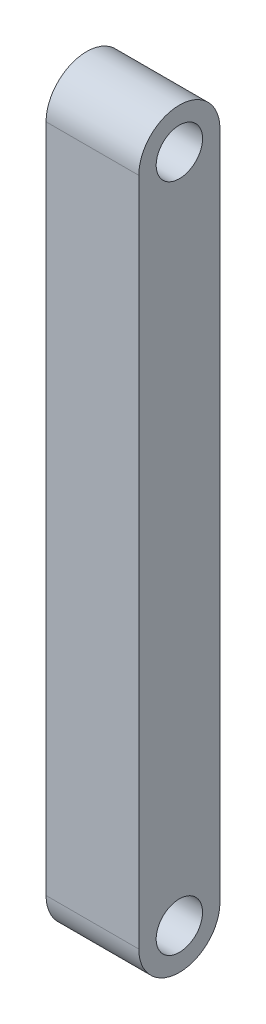
from build123d import *

# Parameters (mm, degrees)
SKETCH1_R           = 2
BOSS_EXTRUDE1_DEPTH = 8


with BuildPart() as part:
    # Sketch1 → Boss-Extrude1 (new body)
    with BuildSketch(Plane(origin=(0, 0, 0), x_dir=(0, 0, -1), z_dir=(1, 0, 0))):
        with BuildLine():
            Line((3.5, -57.8), (3.5, 0))
            ThreePointArc((3.5, 0), (0, 3.5), (-3.5, 0))
            Line((-3.5, 0), (-3.5, -57.8))
            ThreePointArc((-3.5, -57.8), (0, -61.3), (3.5, -57.8))
        make_face()
        Circle(SKETCH1_R, mode=Mode.SUBTRACT)
        with Locations((0, -57.8)):
            Circle(SKETCH1_R, mode=Mode.SUBTRACT)
    extrude(amount=BOSS_EXTRUDE1_DEPTH)


solid = part.part
